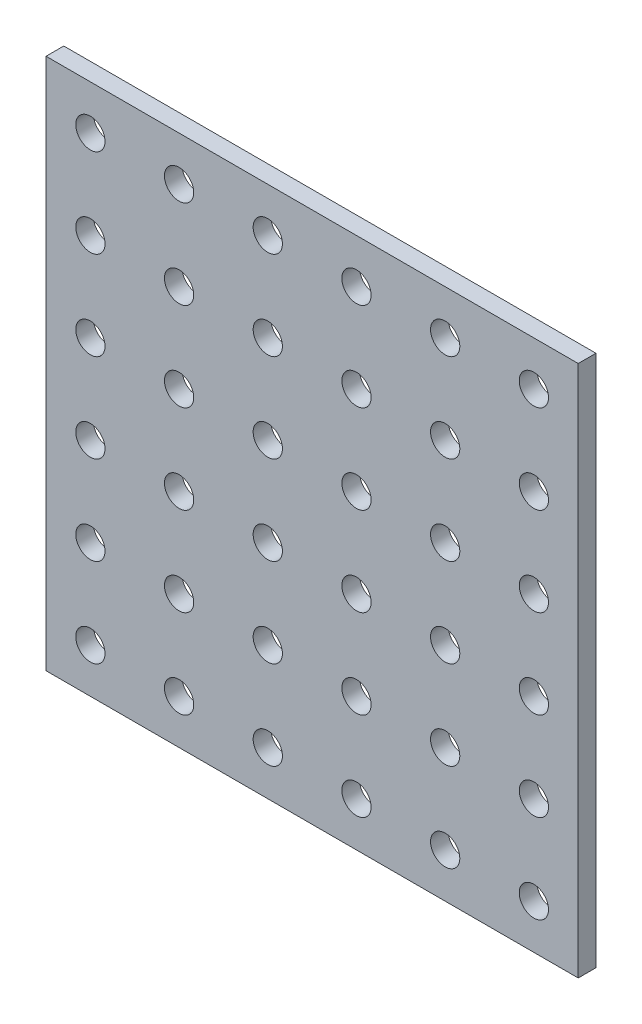
from build123d import *

# Parameters (mm, degrees)
SKETCH1_W            = 60
SKETCH1_H            = 60
BOSS_EXTRUDE1_DEPTH  = 2
SKETCH2_R            = 1.65
CUT_EXTRUDE1_DEPTH   = 3
LPATTERN1_COUNT      = 6
LPATTERN1_PITCH      = 10
LPATTERN1_COUNT_DIR2 = 6
LPATTERN1_PITCH_DIR2 = 10


with BuildPart() as part:
    # Sketch1 → Boss-Extrude1 (new body)
    with BuildSketch(Plane.XY):
        Rectangle(SKETCH1_W, SKETCH1_H)
    extrude(amount=BOSS_EXTRUDE1_DEPTH)

    # Sketch2 → Cut-Extrude1 (cut, through all)
    with BuildSketch(Plane.XY.offset(2)):
        with Locations((-25, 25)):
            Circle(SKETCH2_R)
    cut_extrude1 = extrude(amount=-CUT_EXTRUDE1_DEPTH, mode=Mode.SUBTRACT)

    # LPattern1: Cut-Extrude1 6 × 6
    with Locations(*[(j * LPATTERN1_PITCH_DIR2, -i * LPATTERN1_PITCH, 0) for i in range(LPATTERN1_COUNT) for j in range(LPATTERN1_COUNT_DIR2) if (i, j) != (0, 0)]):
        add(cut_extrude1, mode=Mode.SUBTRACT)


solid = part.part
